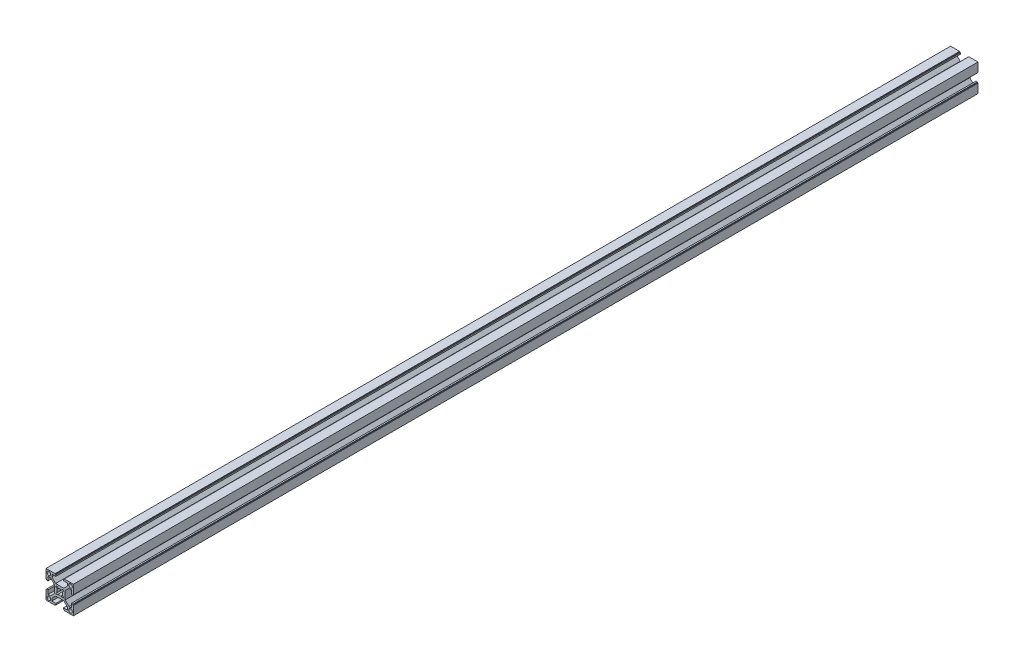
from build123d import *

# Parameters (mm, degrees)
BOSS_EXTRUDE2_DEPTH = 1000
CUT_EXTRUDE1_REACH  = 1002
SKETCH3_R           = 2
SKETCH3_R_2         = 1.999999992


with BuildPart() as part:
    # Sketch2 → Boss-Extrude2 (new body)
    with BuildSketch(Plane.XY):
        Polygon((0, 0), (0, 10), (0.7, 10), (0.7, 10.9), (2.2, 10.9), (2.2, 6.4), (4.9, 6.4), (9.142640687, 10.642640687), (9.142640687, 19.642640687), (4.9, 23.885281374), (2.2, 23.885281374), (2.2, 19.385281374), (0.7, 19.385281374), (0.7, 20.285281374), (0, 20.285281374), (0, 30.285281374), (10, 30.285281374), (10, 29.585281374), (10.9, 29.585281374), (10.9, 28.085281374), (6.4, 28.085281374), (6.4, 25.385281374), (10.642640687, 21.142640687), (19.642640687, 21.142640687), (23.885281374, 25.385281374), (23.885281374, 28.085281374), (19.385281374, 28.085281374), (19.385281374, 29.585281374), (20.285281374, 29.585281374), (20.285281374, 30.285281374), (30.285281374, 30.285281374), (30.285281374, 20.285281374), (29.585281374, 20.285281374), (29.585281374, 19.385281374), (28.085281374, 19.385281374), (28.085281374, 23.885281374), (25.385281374, 23.885281374), (21.142640687, 19.642640687), (21.142640687, 10.642640687), (25.385281374, 6.4), (28.085281374, 6.4), (28.085281374, 10.9), (29.585281374, 10.9), (29.585281374, 10), (30.285281374, 10), (30.285281374, 0), (20.285281374, 0), (20.285281374, 0.7), (19.385281374, 0.7), (19.385281374, 2.2), (23.885281374, 2.2), (23.885281374, 4.9), (19.642640687, 9.142640687), (10.642640687, 9.142640687), (6.4, 4.9), (6.4, 2.2), (10.9, 2.2), (10.9, 0.7), (10, 0.7), (10, 0), align=None)
    extrude(amount=-BOSS_EXTRUDE2_DEPTH)

    # Sketch3 → Cut-Extrude1 (cut, up to next)
    with BuildSketch(Plane.XY, mode=Mode.PRIVATE) as cut_extrude1_sk1:
        with Locations((3.200056686, 27.085348905)):
            Circle(SKETCH3_R)
    cut_extrude1_tool1 = extrude(cut_extrude1_sk1.sketch, amount=-CUT_EXTRUDE1_REACH, mode=Mode.PRIVATE) & part.part
    add(cut_extrude1_tool1.solids().sort_by_distance((3.200057, 27.085349, 0))[0], mode=Mode.SUBTRACT)
    # Sketch3 → Cut-Extrude1 (cut, up to next)
    with BuildSketch(Plane.XY, mode=Mode.PRIVATE) as cut_extrude1_sk2:
        with Locations((27.085224689, 27.085348905)):
            Circle(SKETCH3_R)
    cut_extrude1_tool2 = extrude(cut_extrude1_sk2.sketch, amount=-CUT_EXTRUDE1_REACH, mode=Mode.PRIVATE) & part.part
    add(cut_extrude1_tool2.solids().sort_by_distance((27.085225, 27.085349, 0))[0], mode=Mode.SUBTRACT)
    # Sketch3 → Cut-Extrude1 (cut, up to next)
    with BuildSketch(Plane.XY, mode=Mode.PRIVATE) as cut_extrude1_sk3:
        with Locations((27.085224689, 3.19993247)):
            Circle(SKETCH3_R)
    cut_extrude1_tool3 = extrude(cut_extrude1_sk3.sketch, amount=-CUT_EXTRUDE1_REACH, mode=Mode.PRIVATE) & part.part
    add(cut_extrude1_tool3.solids().sort_by_distance((27.085225, 3.199932, 0))[0], mode=Mode.SUBTRACT)
    # Sketch3 → Cut-Extrude1 (cut, up to next)
    with BuildSketch(Plane.XY, mode=Mode.PRIVATE) as cut_extrude1_sk4:
        with Locations((3.19993247, 3.200056686)):
            Circle(SKETCH3_R_2)
    cut_extrude1_tool4 = extrude(cut_extrude1_sk4.sketch, amount=-CUT_EXTRUDE1_REACH, mode=Mode.PRIVATE) & part.part
    add(cut_extrude1_tool4.solids().sort_by_distance((3.199932, 3.200057, 0))[0], mode=Mode.SUBTRACT)
    # Sketch3 → Cut-Extrude1 (cut, up to next)
    with BuildSketch(Plane.XY, mode=Mode.PRIVATE) as cut_extrude1_sk5:
        with BuildLine():
            Line((11.288922887, 17.865021836), (12.349577543, 16.804356148))
            ThreePointArc((12.349577543, 16.804356148), (11.892640687, 15.142640687), (12.349577543, 13.480925226))
            Line((12.349577543, 13.480925226), (11.288922887, 12.420259538))
            ThreePointArc((11.288922887, 12.420259538), (11.288928771, 11.288888688), (12.420299621, 11.288894572))
            Line((12.420299621, 11.288894572), (13.480954277, 12.34956026))
            ThreePointArc((13.480954277, 12.34956026), (15.142640687, 11.892640687), (16.804327097, 12.34956026))
            Line((16.804327097, 12.34956026), (17.864981753, 11.288894572))
            ThreePointArc((17.864981753, 11.288894572), (18.996352603, 11.288888688), (18.996358487, 12.420259538))
            Line((18.996358487, 12.420259538), (17.935703831, 13.480925226))
            ThreePointArc((17.935703831, 13.480925226), (18.392640687, 15.142640687), (17.935703831, 16.804356148))
            Line((17.935703831, 16.804356148), (18.996358487, 17.865021836))
            ThreePointArc((18.996358487, 17.865021836), (18.996352603, 18.996392686), (17.864981753, 18.996386802))
            Line((17.864981753, 18.996386802), (16.804327097, 17.935721114))
            ThreePointArc((16.804327097, 17.935721114), (15.142640687, 18.392640687), (13.480954277, 17.935721114))
            Line((13.480954277, 17.935721114), (12.420299621, 18.996386802))
            ThreePointArc((12.420299621, 18.996386802), (11.288928771, 18.996392686), (11.288922887, 17.865021836))
        make_face()
    cut_extrude1_tool5 = extrude(cut_extrude1_sk5.sketch, amount=-CUT_EXTRUDE1_REACH, mode=Mode.PRIVATE) & part.part
    add(cut_extrude1_tool5.solids().sort_by_distance((15.142641, 15.142641, 0))[0], mode=Mode.SUBTRACT)


solid = part.part
